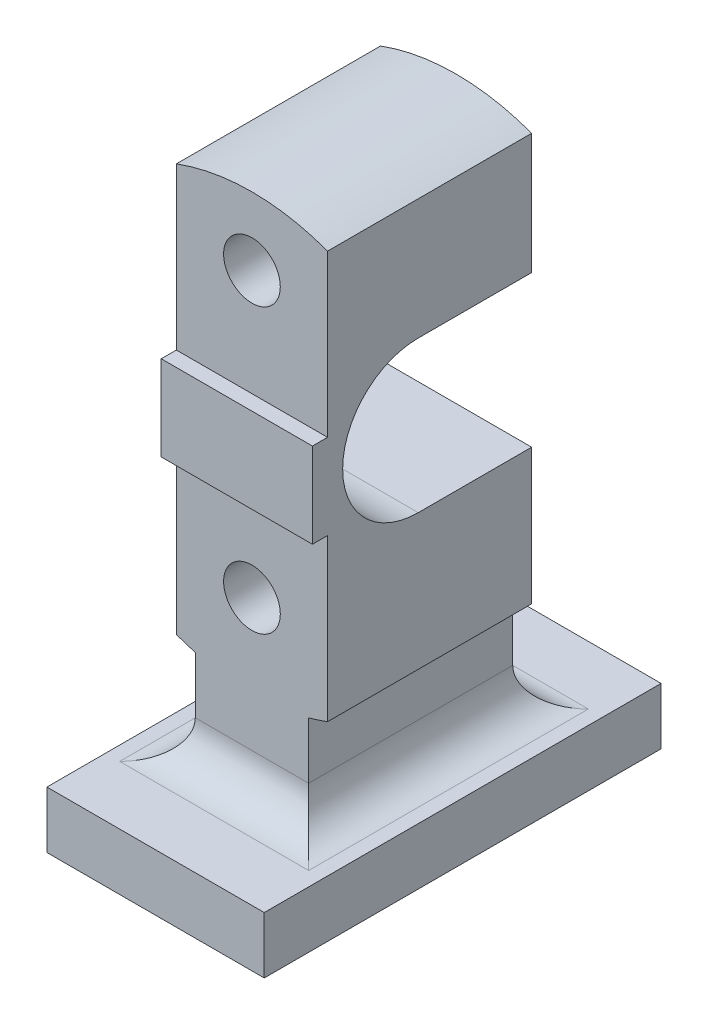
from build123d import *

# Parameters (mm, degrees)
SKETCH3_W               = 115
SKETCH3_H               = 30
BOSS_EXTRUDE2_DEPTH     = 105
BOSS_EXTRUDE3_DEPTH     = 54
SKETCH3_4_W             = 80
SKETCH3_4_H             = 45
BOSS_EXTRUDE4_DEPTH     = 62
CUT_EXTRUDE1_DEPTH      = 239.786793288
CUT_EXTRUDE1_DEPTH_BACK = 239.786793288
FILLET1_R               = 20
SKETCH7_R               = 15
CUT_EXTRUDE2_DEPTH      = 256.098280372


with BuildPart() as part:
    # Sketch3 → Boss-Extrude2 (new, symmetric)
    with BuildSketch(Plane.XY):
        with Locations((0, -176.018016556)):
            Rectangle(SKETCH3_W, SKETCH3_H)
    extrude(amount=BOSS_EXTRUDE2_DEPTH, both=True)

    # Sketch3_3 → Boss-Extrude3 (add, symmetric)
    with BuildSketch(Plane.XY):
        with BuildLine():
            Line((-40, 107.819293264), (-40, -107.819293264))
            ThreePointArc((-40, -107.819293264), (-35.036523196, -109.532835453), (-30, -111.018016556))
            Line((-30, -111.018016556), (-30, -161.018016556))
            Line((-30, -161.018016556), (30, -161.018016556))
            Line((30, -161.018016556), (30, -111.018016556))
            ThreePointArc((30, -111.018016556), (35.036523196, -109.532835453), (40, -107.819293264))
            Line((40, -107.819293264), (40, 107.819293264))
            ThreePointArc((40, 107.819293264), (0, 115), (-40, 107.819293264))
        make_face()
    extrude(amount=BOSS_EXTRUDE3_DEPTH, both=True)

    # Sketch3_4 → Boss-Extrude4 (add)
    with BuildSketch(Plane.XY):
        Rectangle(SKETCH3_4_W, SKETCH3_4_H)
    extrude(amount=BOSS_EXTRUDE4_DEPTH)

    # Sketch5 → Cut-Extrude1 (cut, two sides: drawn at the far end of the back side and taken through both)
    with BuildSketch(Plane(origin=(40, 0, 0), x_dir=(0, 0, -1), z_dir=(1, 0, 0)).offset(-CUT_EXTRUDE1_DEPTH_BACK)):
        with BuildLine():
            Line((631.471585192, -36.018016556), (54, -36.018016556))
            Line((54, -36.018016556), (-6, -36.018016556))
            ThreePointArc((-6, -36.018016556), (-46, 3.981983444), (-6, 43.981983444))
            Line((-6, 43.981983444), (54, 43.981983444))
            Line((54, 43.981983444), (631.471585192, 43.981983444))
            Line((631.471585192, 43.981983444), (1786.414755575, 43.981983444))
            Line((1786.414755575, 43.981983444), (1786.414755575, -36.018016556))
            Line((1786.414755575, -36.018016556), (631.471585192, -36.018016556))
        make_face()
    extrude(amount=CUT_EXTRUDE1_DEPTH + CUT_EXTRUDE1_DEPTH_BACK, mode=Mode.SUBTRACT)

    # Fillet1
    fillet1_edges = [part.edges().sort_by_distance(p)[0] for p in [
        (0, -161.018016556, 54),
        (30, -161.018016556, 0),
        (0, -161.018016556, -54),
        (-30, -161.018016556, 0),
    ]]
    fillet(fillet1_edges, radius=FILLET1_R)

    # Sketch7 → Cut-Extrude2 (cut, through all)
    with BuildSketch(Plane.XY.offset(54)):
        with Locations((0, -71.018016556)):
            Circle(SKETCH7_R)
        with Locations((0, 78.981983444)):
            Circle(SKETCH7_R)
    extrude(amount=-CUT_EXTRUDE2_DEPTH, mode=Mode.SUBTRACT)


solid = part.part
